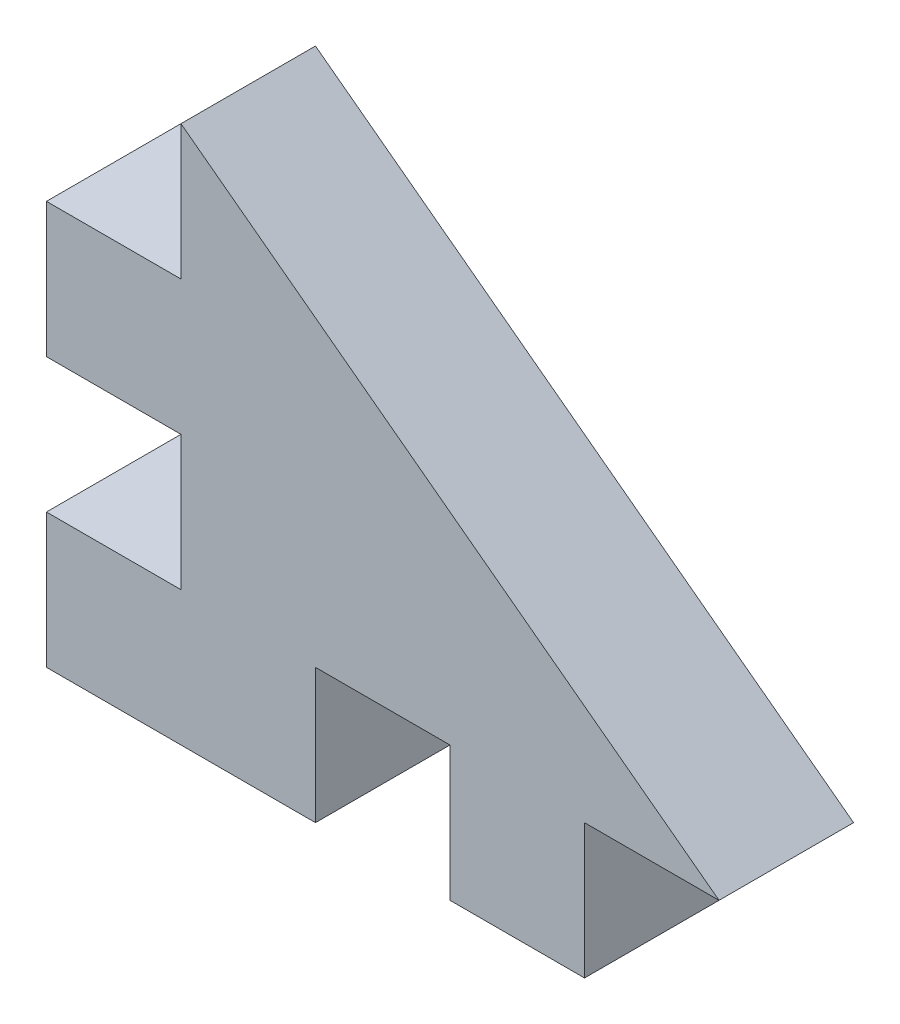
from build123d import *

# Parameters (mm, degrees)
ESQUISSE1_W             = 25
ESQUISSE1_H             = 20
BOSS_EXTRU_1_DEPTH      = 5
ESQUISSE2_W             = 5
ESQUISSE2_H             = 5
ENL_V_MAT_EXTRU_4_DEPTH = 5


with BuildPart() as part:
    # Esquisse1 → Boss.-Extru.1 (new body)
    with BuildSketch(Plane.XY):
        with Locations((-30.743041797, 4.26352657)):
            Rectangle(ESQUISSE1_W, ESQUISSE1_H)
    extrude(amount=BOSS_EXTRU_1_DEPTH)

    # Esquisse2 → Enlèv. mat.-Extru.4 (cut)
    with BuildSketch(Plane.XY.offset(5)):
        Polygon((-38.243041797, 14.26352657), (-18.243041797, -0.73647343), (-18.243041797, 14.26352657), align=None)
        with Locations((-40.743041797, 11.76352657)):
            Rectangle(ESQUISSE2_W, ESQUISSE2_H)
        with Locations((-40.743041797, 1.76352657)):
            Rectangle(ESQUISSE2_W, ESQUISSE2_H)
        with Locations((-30.743041797, -3.23647343)):
            Rectangle(ESQUISSE2_W, ESQUISSE2_H)
        with Locations((-20.743041797, -3.23647343)):
            Rectangle(ESQUISSE2_W, ESQUISSE2_H)
    extrude(amount=-ENL_V_MAT_EXTRU_4_DEPTH, mode=Mode.SUBTRACT)


solid = part.part
